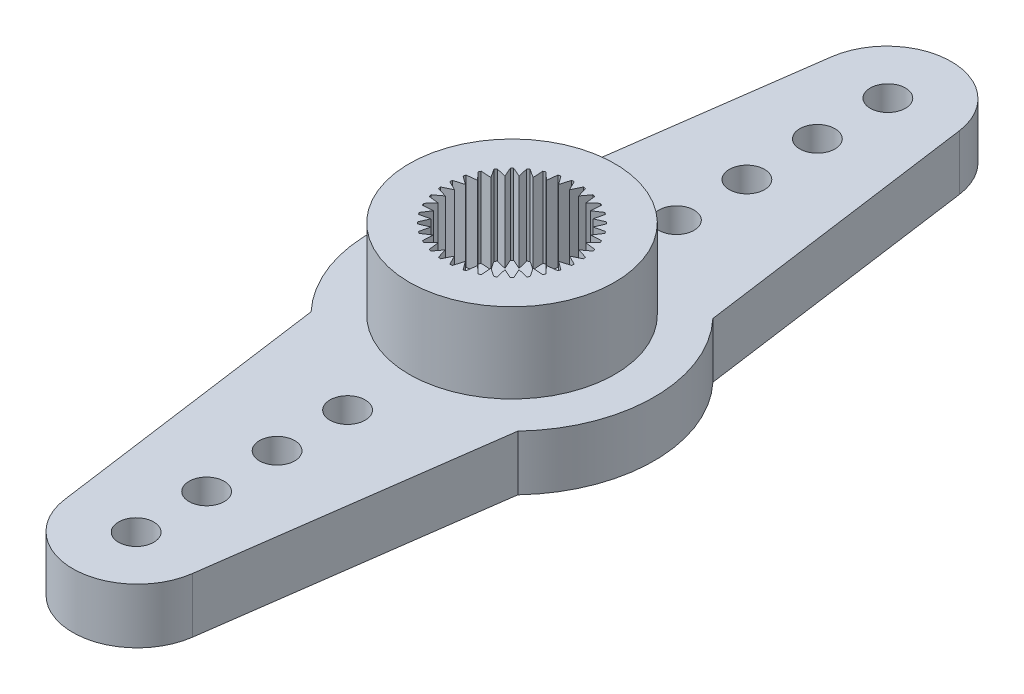
from build123d import *

# Parameters (mm, degrees)
BOSS_EXTRUDE1_DEPTH                                 = 2.35
SKETCH2_R                                           = 4.375
BOSS_EXTRUDE2_DEPTH                                 = 3.4
CUT_EXTRUDE1_DEPTH                                  = 3.4
HOLE1_D                                             = 8.8
HOLE1_DEPTH                                         = 0.3
SKETCH6_W                                           = 3.25
SKETCH6_H                                           = 0.3
F_00_CLEARANCE_HOLE1_D                              = 1.5
F_00_CLEARANCE_HOLE1_DEPTH                          = 2.35
CBORE_FOR_3_BINDING_HEAD_MACHINE_SCREW1_D           = 3
CBORE_FOR_3_BINDING_HEAD_MACHINE_SCREW1_DEPTH       = 5.75
CBORE_FOR_3_BINDING_HEAD_MACHINE_SCREW1_CBORE_D     = 5.5
CBORE_FOR_3_BINDING_HEAD_MACHINE_SCREW1_CBORE_DEPTH = 0.3


with BuildPart() as part:
    # Sketch1 → Boss-Extrude1 (new body)
    with BuildSketch(Plane(origin=(0, 2.35, 0), x_dir=(1, 0, 0), z_dir=(0, 1, 0))):
        with BuildLine():
            Line((2.724307673, -16.32503027), (4.4, -4.152408939))
            ThreePointArc((4.4, -4.152408939), (6.05, 0), (4.4, 4.152408939))
            Line((4.4, 4.152408939), (2.724307673, 16.32503027))
            ThreePointArc((2.724307673, 16.32503027), (0, 18.7), (-2.724307673, 16.32503027))
            Line((-2.724307673, 16.32503027), (-4.4, 4.152408939))
            ThreePointArc((-4.4, 4.152408939), (-6.05, 0), (-4.4, -4.152408939))
            Line((-4.4, -4.152408939), (-2.724307673, -16.32503027))
            ThreePointArc((-2.724307673, -16.32503027), (0, -18.7), (2.724307673, -16.32503027))
        make_face()
    extrude(amount=-BOSS_EXTRUDE1_DEPTH)

    # Sketch2 → Boss-Extrude2 (add)
    with BuildSketch(Plane(origin=(0, 2.35, 0), x_dir=(-1, 0, 0), z_dir=(0, 1, 0))):
        Circle(SKETCH2_R)
    extrude(amount=BOSS_EXTRUDE2_DEPTH)

    # Sketch3 → Cut-Extrude1 (cut)
    with BuildSketch(Plane(origin=(0, 5.75, 0), x_dir=(-1, 0, 0), z_dir=(0, 1, 0))):
        with BuildLine():
            Line((0.687336745, 2.765875666), (0.425438035, 2.412778995))
            Line((0.425438035, 2.412778995), (0.300099924, 2.834155965))
            ThreePointArc((0.300099924, 2.834155965), (0.248393867, 2.83915489), (0.196605286, 2.843210573))
            Line((0.196605286, 2.843210573), (0, 2.45))
            Line((0, 2.45), (-0.196605286, 2.843210573))
            ThreePointArc((-0.196605286, 2.843210573), (-0.248393867, 2.83915489), (-0.300099924, 2.834155965))
            Line((-0.300099924, 2.834155965), (-0.425438035, 2.412778995))
            Line((-0.425438035, 2.412778995), (-0.687336745, 2.765875666))
            ThreePointArc((-0.687336745, 2.765875666), (-0.737634279, 2.752888605), (-0.787686751, 2.738986963))
            Line((-0.787686751, 2.738986963), (-0.837949351, 2.302246921))
            Line((-0.837949351, 2.302246921), (-1.157183824, 2.604501026))
            ThreePointArc((-1.157183824, 2.604501026), (-1.204462046, 2.582977193), (-1.251340114, 2.560595228))
            Line((-1.251340114, 2.560595228), (-1.225, 2.121762239))
            Line((-1.225, 2.121762239), (-1.591870459, 2.363989941))
            ThreePointArc((-1.591870459, 2.363989941), (-1.634692844, 2.334583326), (-1.676972141, 2.304401102))
            Line((-1.676972141, 2.304401102), (-1.574829644, 1.876808886))
            Line((-1.574829644, 1.876808886), (-1.978188915, 2.051650218))
            ThreePointArc((-1.978188915, 2.051650218), (-2.015254326, 2.015254326), (-2.051650218, 1.978188915))
            Line((-2.051650218, 1.978188915), (-1.876808886, 1.574829644))
            Line((-1.876808886, 1.574829644), (-2.304401102, 1.676972141))
            ThreePointArc((-2.304401102, 1.676972141), (-2.334583326, 1.634692844), (-2.363989941, 1.591870459))
            Line((-2.363989941, 1.591870459), (-2.121762239, 1.225))
            Line((-2.121762239, 1.225), (-2.560595228, 1.251340114))
            ThreePointArc((-2.560595228, 1.251340114), (-2.582977193, 1.204462046), (-2.604501026, 1.157183824))
            Line((-2.604501026, 1.157183824), (-2.302246921, 0.837949351))
            Line((-2.302246921, 0.837949351), (-2.738986963, 0.787686751))
            ThreePointArc((-2.738986963, 0.787686751), (-2.752888605, 0.737634279), (-2.765875666, 0.687336745))
            Line((-2.765875666, 0.687336745), (-2.412778995, 0.425438035))
            Line((-2.412778995, 0.425438035), (-2.834155965, 0.300099924))
            ThreePointArc((-2.834155965, 0.300099924), (-2.83915489, 0.248393867), (-2.843210573, 0.196605286))
            Line((-2.843210573, 0.196605286), (-2.45, 0))
            Line((-2.45, 0), (-2.843210573, -0.196605286))
            ThreePointArc((-2.843210573, -0.196605286), (-2.83915489, -0.248393867), (-2.834155965, -0.300099924))
            Line((-2.834155965, -0.300099924), (-2.412778995, -0.425438035))
            Line((-2.412778995, -0.425438035), (-2.765875666, -0.687336745))
            ThreePointArc((-2.765875666, -0.687336745), (-2.752888605, -0.737634279), (-2.738986963, -0.787686751))
            Line((-2.738986963, -0.787686751), (-2.302246921, -0.837949351))
            Line((-2.302246921, -0.837949351), (-2.604501026, -1.157183824))
            ThreePointArc((-2.604501026, -1.157183824), (-2.582977193, -1.204462046), (-2.560595228, -1.251340114))
            Line((-2.560595228, -1.251340114), (-2.121762239, -1.225))
            Line((-2.121762239, -1.225), (-2.363989941, -1.591870459))
            ThreePointArc((-2.363989941, -1.591870459), (-2.334583326, -1.634692844), (-2.304401102, -1.676972141))
            Line((-2.304401102, -1.676972141), (-1.876808886, -1.574829644))
            Line((-1.876808886, -1.574829644), (-2.051650218, -1.978188915))
            ThreePointArc((-2.051650218, -1.978188915), (-2.015254326, -2.015254326), (-1.978188915, -2.051650218))
            Line((-1.978188915, -2.051650218), (-1.574829644, -1.876808886))
            Line((-1.574829644, -1.876808886), (-1.676972141, -2.304401102))
            ThreePointArc((-1.676972141, -2.304401102), (-1.634692844, -2.334583326), (-1.591870459, -2.363989941))
            Line((-1.591870459, -2.363989941), (-1.225, -2.121762239))
            Line((-1.225, -2.121762239), (-1.251340114, -2.560595228))
            ThreePointArc((-1.251340114, -2.560595228), (-1.204462046, -2.582977193), (-1.157183824, -2.604501026))
            Line((-1.157183824, -2.604501026), (-0.837949351, -2.302246921))
            Line((-0.837949351, -2.302246921), (-0.787686751, -2.738986963))
            ThreePointArc((-0.787686751, -2.738986963), (-0.737634279, -2.752888605), (-0.687336745, -2.765875666))
            Line((-0.687336745, -2.765875666), (-0.425438035, -2.412778995))
            Line((-0.425438035, -2.412778995), (-0.300099924, -2.834155965))
            ThreePointArc((-0.300099924, -2.834155965), (-0.248393867, -2.83915489), (-0.196605286, -2.843210573))
            Line((-0.196605286, -2.843210573), (0, -2.45))
            Line((0, -2.45), (0.196605286, -2.843210573))
            ThreePointArc((0.196605286, -2.843210573), (0.248393867, -2.83915489), (0.300099924, -2.834155965))
            Line((0.300099924, -2.834155965), (0.425438035, -2.412778995))
            Line((0.425438035, -2.412778995), (0.687336745, -2.765875666))
            ThreePointArc((0.687336745, -2.765875666), (0.737634279, -2.752888605), (0.787686751, -2.738986963))
            Line((0.787686751, -2.738986963), (0.837949351, -2.302246921))
            Line((0.837949351, -2.302246921), (1.157183824, -2.604501026))
            ThreePointArc((1.157183824, -2.604501026), (1.204462046, -2.582977193), (1.251340114, -2.560595228))
            Line((1.251340114, -2.560595228), (1.225, -2.121762239))
            Line((1.225, -2.121762239), (1.591870459, -2.363989941))
            ThreePointArc((1.591870459, -2.363989941), (1.634692844, -2.334583326), (1.676972141, -2.304401102))
            Line((1.676972141, -2.304401102), (1.574829644, -1.876808886))
            Line((1.574829644, -1.876808886), (1.978188915, -2.051650218))
            ThreePointArc((1.978188915, -2.051650218), (2.015254326, -2.015254326), (2.051650218, -1.978188915))
            Line((2.051650218, -1.978188915), (1.876808886, -1.574829644))
            Line((1.876808886, -1.574829644), (2.304401102, -1.676972141))
            ThreePointArc((2.304401102, -1.676972141), (2.334583326, -1.634692844), (2.363989941, -1.591870459))
            Line((2.363989941, -1.591870459), (2.121762239, -1.225))
            Line((2.121762239, -1.225), (2.560595228, -1.251340114))
            ThreePointArc((2.560595228, -1.251340114), (2.582977193, -1.204462046), (2.604501026, -1.157183824))
            Line((2.604501026, -1.157183824), (2.302246921, -0.837949351))
            Line((2.302246921, -0.837949351), (2.738986963, -0.787686751))
            ThreePointArc((2.738986963, -0.787686751), (2.752888605, -0.737634279), (2.765875666, -0.687336745))
            Line((2.765875666, -0.687336745), (2.412778995, -0.425438035))
            Line((2.412778995, -0.425438035), (2.834155965, -0.300099924))
            ThreePointArc((2.834155965, -0.300099924), (2.83915489, -0.248393867), (2.843210573, -0.196605286))
            Line((2.843210573, -0.196605286), (2.45, 0))
            Line((2.45, 0), (2.843210573, 0.196605286))
            ThreePointArc((2.843210573, 0.196605286), (2.83915489, 0.248393867), (2.834155965, 0.300099924))
            Line((2.834155965, 0.300099924), (2.412778995, 0.425438035))
            Line((2.412778995, 0.425438035), (2.765875666, 0.687336745))
            ThreePointArc((2.765875666, 0.687336745), (2.752888605, 0.737634279), (2.738986963, 0.787686751))
            Line((2.738986963, 0.787686751), (2.302246921, 0.837949351))
            Line((2.302246921, 0.837949351), (2.604501026, 1.157183824))
            ThreePointArc((2.604501026, 1.157183824), (2.582977193, 1.204462046), (2.560595228, 1.251340114))
            Line((2.560595228, 1.251340114), (2.121762239, 1.225))
            Line((2.121762239, 1.225), (2.363989941, 1.591870459))
            ThreePointArc((2.363989941, 1.591870459), (2.334583326, 1.634692844), (2.304401102, 1.676972141))
            Line((2.304401102, 1.676972141), (1.876808886, 1.574829644))
            Line((1.876808886, 1.574829644), (2.051650218, 1.978188915))
            ThreePointArc((2.051650218, 1.978188915), (2.015254326, 2.015254326), (1.978188915, 2.051650218))
            Line((1.978188915, 2.051650218), (1.574829644, 1.876808886))
            Line((1.574829644, 1.876808886), (1.676972141, 2.304401102))
            ThreePointArc((1.676972141, 2.304401102), (1.634692844, 2.334583326), (1.591870459, 2.363989941))
            Line((1.591870459, 2.363989941), (1.225, 2.121762239))
            Line((1.225, 2.121762239), (1.251340114, 2.560595228))
            ThreePointArc((1.251340114, 2.560595228), (1.204462046, 2.582977193), (1.157183824, 2.604501026))
            Line((1.157183824, 2.604501026), (0.837949351, 2.302246921))
            Line((0.837949351, 2.302246921), (0.787686751, 2.738986963))
            ThreePointArc((0.787686751, 2.738986963), (0.737634279, 2.752888605), (0.687336745, 2.765875666))
        make_face()
    extrude(amount=-CUT_EXTRUDE1_DEPTH, mode=Mode.SUBTRACT)

    # Hole1
    with Locations(Plane(origin=(0, 0, 0), x_dir=(-1, 0, 0), z_dir=(0, -1, 0))):
        with Locations((0, 0)):
            Hole(HOLE1_D / 2, depth=HOLE1_DEPTH)

    # Sketch6 → Revolve1 (revolve)
    with BuildSketch(Plane.XY):
        with Locations((1.625, 0.15)):
            Rectangle(SKETCH6_W, SKETCH6_H)
    revolve(axis=Axis((0, 0.3, 0), (0, -1, 0)))

    # #00 Clearance Hole1
    with Locations(Plane(origin=(0, 2.35, 0), x_dir=(1, 0, 0), z_dir=(0, 1, 0))):
        with Locations((0, -7), (0, 16), (0, -10), (0, -13), (0, -16), (0, 13), (0, 10), (0, 7)):
            Hole(F_00_CLEARANCE_HOLE1_D / 2, depth=F_00_CLEARANCE_HOLE1_DEPTH)

    # CBORE for #3 Binding Head Machine Screw1
    with Locations(Plane(origin=(0, 0, 0), x_dir=(-1, 0, 0), z_dir=(0, -1, 0))):
        with Locations((0, 0)):
            CounterBoreHole(CBORE_FOR_3_BINDING_HEAD_MACHINE_SCREW1_D / 2, CBORE_FOR_3_BINDING_HEAD_MACHINE_SCREW1_CBORE_D / 2, CBORE_FOR_3_BINDING_HEAD_MACHINE_SCREW1_CBORE_DEPTH, depth=CBORE_FOR_3_BINDING_HEAD_MACHINE_SCREW1_DEPTH)


solid = part.part
